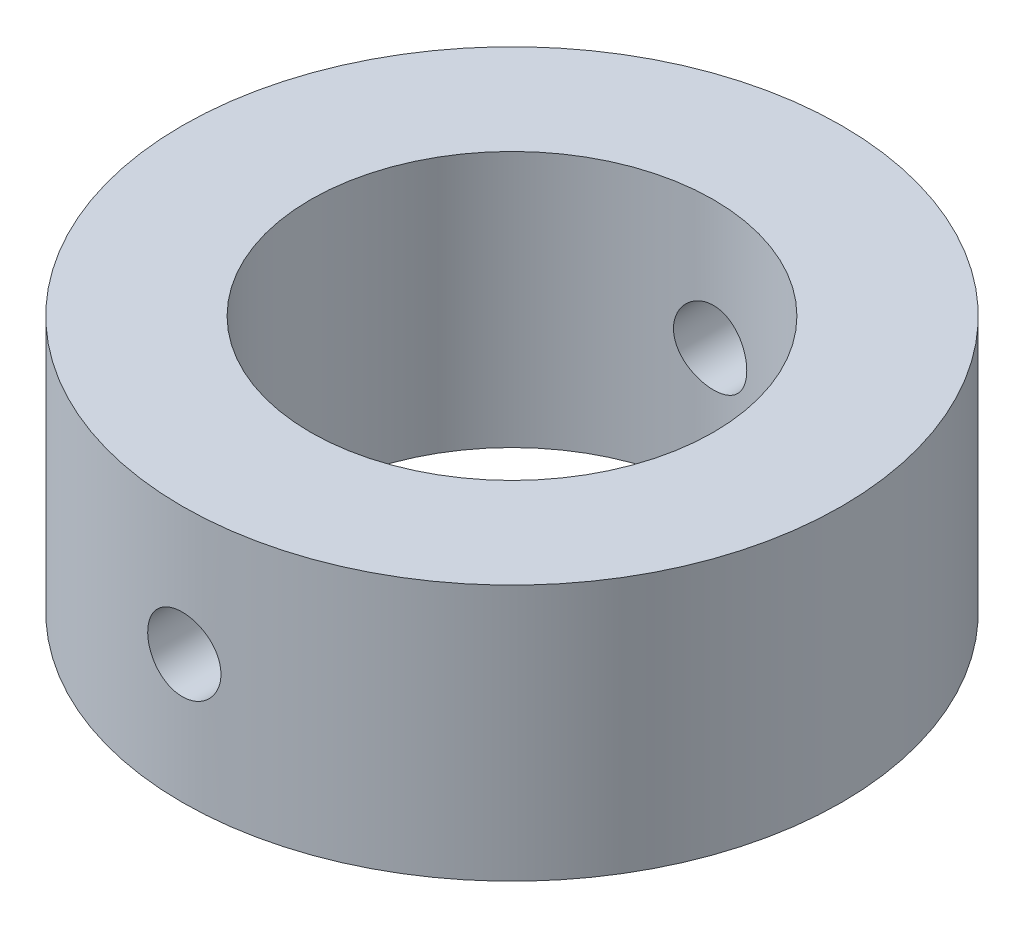
from build123d import *

# Parameters (mm, degrees)
SKETCH1_W          = 7
SKETCH1_H          = 14
SKETCH2_R          = 2
CUT_EXTRUDE1_DEPTH = 33


with BuildPart() as part:
    # Sketch1 → Revolve1 (revolve)
    with BuildSketch(Plane.XY):
        with Locations((14.5, 0)):
            Rectangle(SKETCH1_W, SKETCH1_H)
    revolve(axis=Axis((0, 17.553846154, 0), (0, -1, 0)))

    # Sketch2 → Cut-Extrude1 (cut, symmetric)
    with BuildSketch(Plane.XY):
        Circle(SKETCH2_R)
    extrude(amount=CUT_EXTRUDE1_DEPTH, both=True, mode=Mode.SUBTRACT)


solid = part.part
